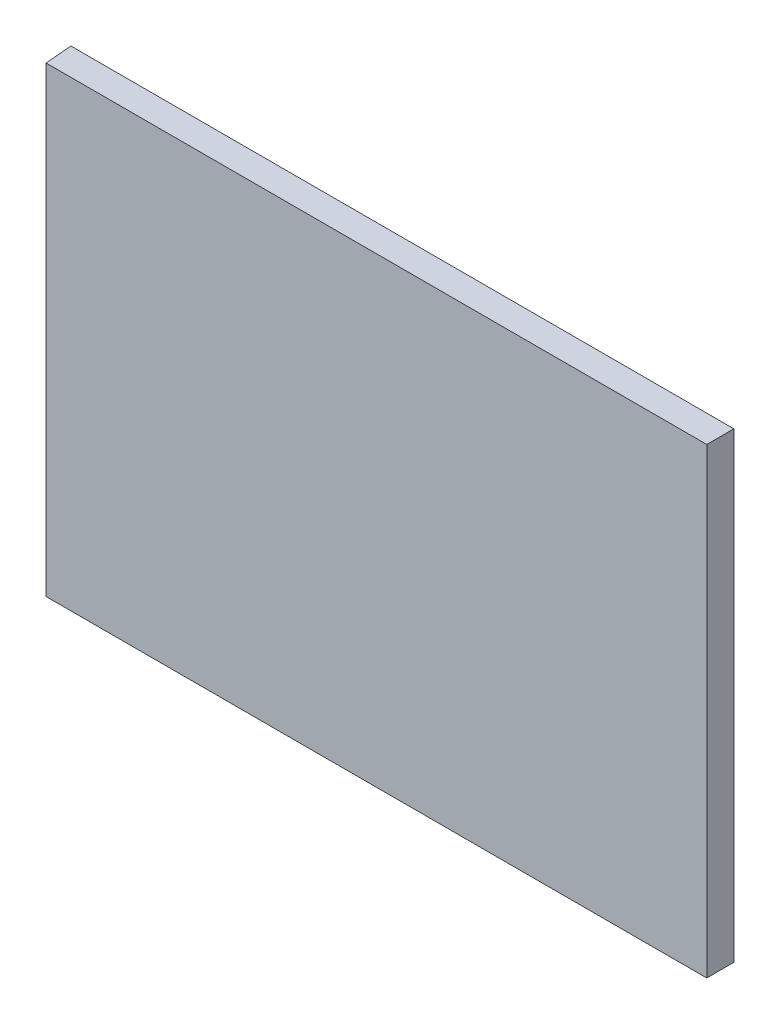
from build123d import *

# Parameters (mm, degrees)
SKETCH_4_W               = 25.95
SKETCH_4_H               = 21.04
EXTRUDE_1_DEPTH          = 1
CUT_EXTRUDE_1_DEPTH      = 22.04
CUT_EXTRUDE_2_DEPTH      = 22.04
CUT_EXTRUDE_4_DEPTH      = 15.911872331
CUT_EXTRUDE_4_DEPTH_BACK = 12.038127669
CUT_EXTRUDE_5_DEPTH      = 15.911872331
CUT_EXTRUDE_5_DEPTH_BACK = 12.038127669
CUT_EXTRUDE_6_DEPTH      = 1
SKETCH_14_W              = 1
SKETCH_14_H              = 2
CUT_EXTRUDE_7_DEPTH      = 10


with BuildPart() as part:
    # 草图4 → 凸台-拉伸1 (new body)
    with BuildSketch(Plane.XY):
        with Locations((1.936872331, -1.52)):
            Rectangle(SKETCH_4_W, SKETCH_4_H)
    extrude(amount=EXTRUDE_1_DEPTH)

    # 草图6 → 切除-拉伸1 (cut, through all)
    with BuildSketch(Plane(origin=(0, 9, 0), x_dir=(1, 0, 0), z_dir=(0, 1, 0))):
        Polygon((-11.038127669, 0), (-11.038127669, -1), (-10.950639006, -1), align=None)
    extrude(amount=-CUT_EXTRUDE_1_DEPTH, mode=Mode.SUBTRACT)

    # 草图7 → 切除-拉伸2 (cut, through all)
    with BuildSketch(Plane(origin=(0, 9, 0), x_dir=(1, 0, 0), z_dir=(0, 1, 0))):
        Polygon((14.911872331, -1), (14.894417266, 0), (14.911872331, 0), align=None)
    extrude(amount=-CUT_EXTRUDE_2_DEPTH, mode=Mode.SUBTRACT)

    # 草图11 → 切除-拉伸4 (cut, two sides)
    with BuildSketch(Plane(origin=(0, 0, 0), x_dir=(0, 0, -1), z_dir=(1, 0, 0))) as cut_extrude_4_sk:
        Polygon((-1, -12.04), (0, -12.04), (0, -12.022544935), align=None)
    extrude(amount=CUT_EXTRUDE_4_DEPTH, mode=Mode.SUBTRACT)
    extrude(cut_extrude_4_sk.sketch, amount=-CUT_EXTRUDE_4_DEPTH_BACK, mode=Mode.SUBTRACT)

    # 草图12 → 切除-拉伸5 (cut, two sides)
    with BuildSketch(Plane(origin=(0, 0, 0), x_dir=(0, 0, -1), z_dir=(1, 0, 0))) as cut_extrude_5_sk:
        Polygon((-1, 9), (0, 9), (0, 8.982544935), align=None)
    extrude(amount=CUT_EXTRUDE_5_DEPTH, mode=Mode.SUBTRACT)
    extrude(cut_extrude_5_sk.sketch, amount=-CUT_EXTRUDE_5_DEPTH_BACK, mode=Mode.SUBTRACT)

    # 草图13 → 切除-拉伸6 (cut)
    with BuildSketch(Plane.XY.offset(1)):
        Polygon((-10.950639006, 7), (13.411872331, 7), (13.411872331, -10.04), (-10.950639006, -10.04), (-10.950639006, -12.04), (14.911872331, -12.04), (14.911872331, 9), (-10.950639006, 9), align=None)
    extrude(amount=-CUT_EXTRUDE_6_DEPTH, mode=Mode.SUBTRACT)

    # 草图14 → 切除-拉伸7 (cut)
    with BuildSketch(Plane(origin=(-10.950639006, 0, 0), x_dir=(0, 0, -1), z_dir=(1, 0, 0))):
        with Locations((-0.5, 8)):
            Rectangle(SKETCH_14_W, SKETCH_14_H)
        with Locations((-0.5, -11.04)):
            Rectangle(SKETCH_14_W, SKETCH_14_H)
    extrude(amount=-CUT_EXTRUDE_7_DEPTH, mode=Mode.SUBTRACT)


solid = part.part
